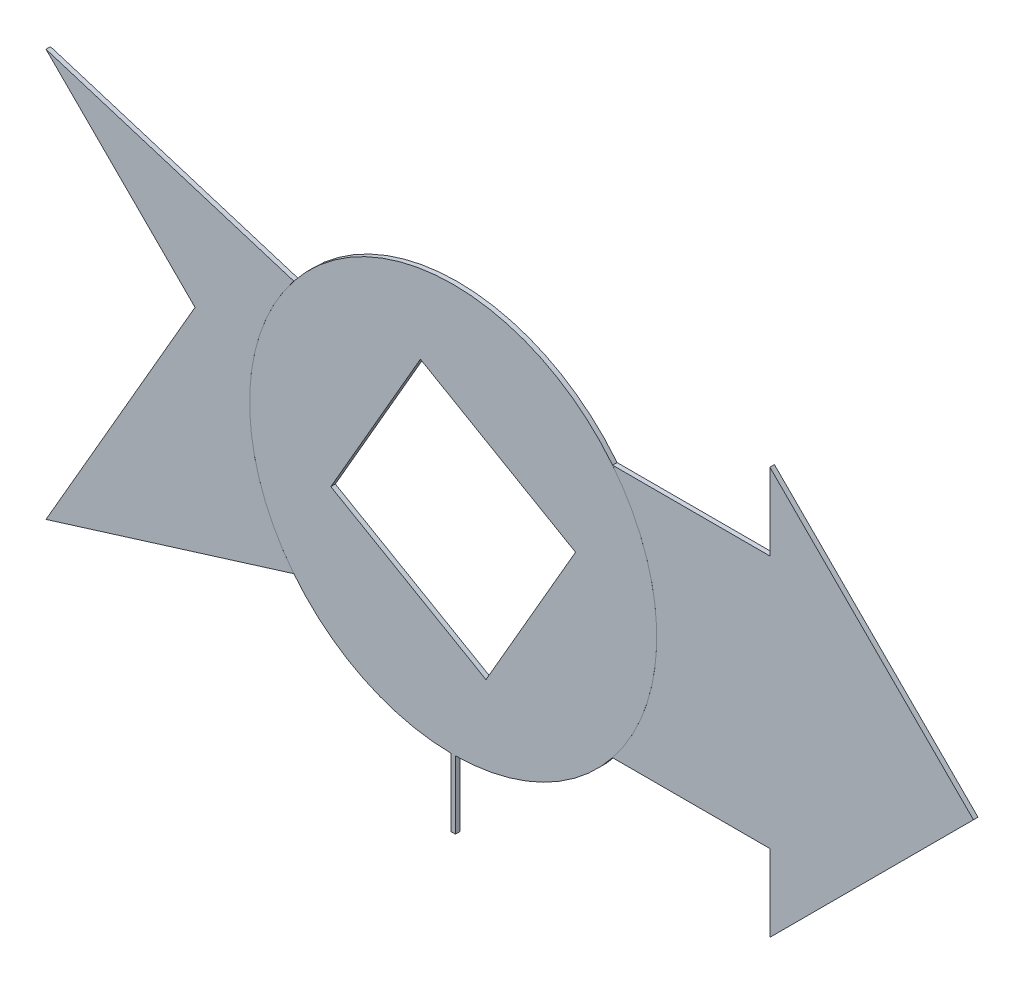
from build123d import *

# Parameters (mm, degrees)
CENTRAL_CIRCLE_DEPTH = 1
BACK_OF_ARROW_DEPTH  = 1
FRONT_OF_ARROW_DEPTH = 1
SQUARE_HOLE_DEPTH    = 1


with BuildPart() as part:
    # Sketch1 → Central circle (new body)
    with BuildSketch(Plane.XY):
        with BuildLine():
            Line((89.5, 15.002777864), (89.5, 0))
            Line((89.5, 0), (90.5, 0))
            Line((90.5, 0), (90.5, 15.002777864))
            ThreePointArc((90.5, 15.002777864), (90, 105), (89.5, 15.002777864))
        make_face()
    extrude(amount=CENTRAL_CIRCLE_DEPTH)

    # Sketch4 → Square hole (cut)
    with BuildSketch(Plane.XY.offset(1)):
        Polygon((62.954076864, 52.753066737), (97.246933263, 32.954076864), (117.045923136, 67.246933263), (82.753066737, 87.045923136), align=None)
    extrude(amount=-SQUARE_HOLE_DEPTH, mode=Mode.SUBTRACT)


with BuildPart() as body_2:
    # Sketch2 → Back of arrow (new body)
    with BuildSketch(Plane.XY):
        with BuildLine():
            Line((0, 15), (54.772170092, 32))
            ThreePointArc((54.772170092, 32), (45, 60), (54.772170092, 88))
            Line((54.772170092, 88), (0, 105))
            Line((0, 105), (32.942286341, 72.057713659))
            Line((32.942286341, 72.057713659), (0, 15))
        make_face()
    extrude(amount=BACK_OF_ARROW_DEPTH)


with BuildPart() as body_3:
    # Sketch3 → Front of arrow (new body)
    with BuildSketch(Plane.XY):
        with BuildLine():
            Line((160, 105), (205, 60))
            Line((205, 60), (160, 15))
            Line((160, 15), (160, 32))
            Line((160, 32), (125.227829908, 32))
            ThreePointArc((125.227829908, 32), (135, 60), (125.227829908, 88))
            Line((125.227829908, 88), (160, 88))
            Line((160, 88), (160, 105))
        make_face()
    extrude(amount=FRONT_OF_ARROW_DEPTH)


solid = Compound([part.part, body_2.part, body_3.part])
